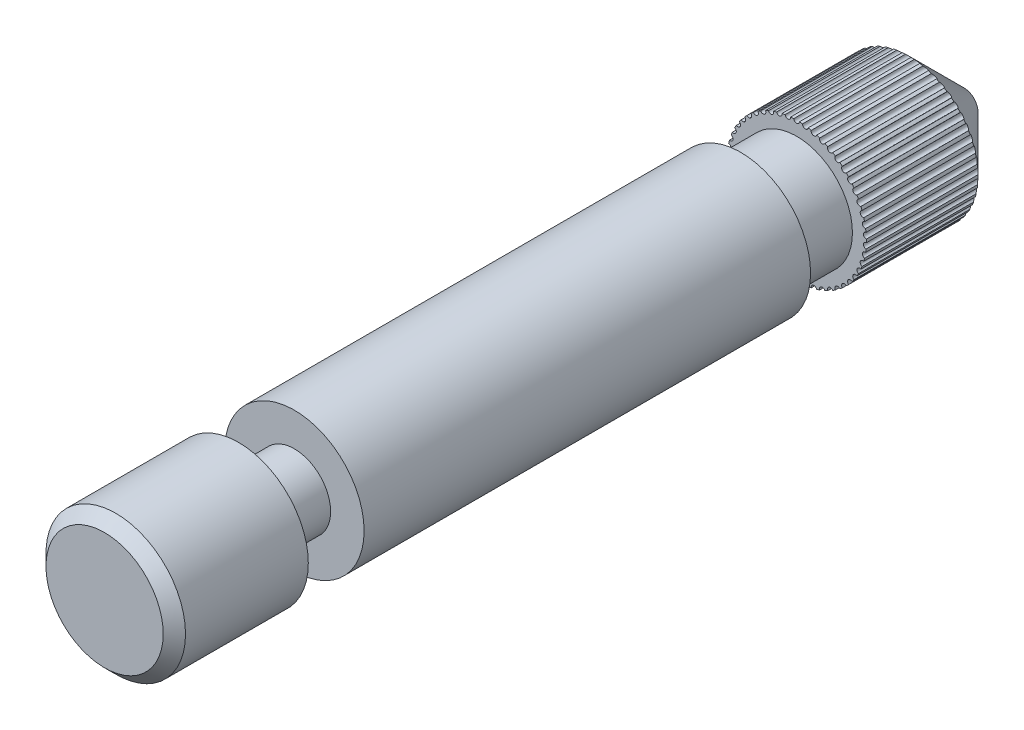
from build123d import *

# Parameters (mm, degrees)
SKETCH1_R           = 1.25
BOSS_EXTRUDE1_DEPTH = 15.4
SKETCH2_W           = 1
SKETCH2_H           = 0.6
SKETCH3_W           = 1
SKETCH3_H           = 0.25
CHAMFER1_SIZE       = 1
CHAMFER2_SIZE       = 0.2
CUT_EXTRUDE2_START  = -2.05
SKETCH4_R           = 0.05
CUT_EXTRUDE2_DEPTH  = 2.05
CIRPATTERN2_COUNT   = 50


with BuildPart() as part:
    # Sketch1 → Boss-Extrude1 (new body)
    with BuildSketch(Plane.XY):
        Circle(SKETCH1_R)
    extrude(amount=-BOSS_EXTRUDE1_DEPTH)

    # Sketch2 → Cut-Revolve1 (revolve, cut)
    with BuildSketch(Plane(origin=(0, 0, 0), x_dir=(0, 0, -1), z_dir=(1, 0, 0))):
        with Locations((2.9, 0.95)):
            Rectangle(SKETCH2_W, SKETCH2_H)
    revolve(axis=Axis((0, 0, 0), (0, 0, -1)), mode=Mode.SUBTRACT)

    # Sketch3 → Cut-Revolve2 (revolve, cut)
    with BuildSketch(Plane(origin=(0, 0, 0), x_dir=(0, 0, -1), z_dir=(1, 0, 0))):
        with Locations((11.9, 1.125)):
            Rectangle(SKETCH3_W, SKETCH3_H)
    revolve(axis=Axis((0, 0, 0), (0, 0, -1)), mode=Mode.SUBTRACT)

    # Chamfer1
    chamfer1_edges = [part.edges().sort_by_distance(p)[0] for p in [
        (-1.25, 0, -15.4),
    ]]
    chamfer(chamfer1_edges, length=CHAMFER1_SIZE)

    # Chamfer2
    chamfer2_edges = [part.edges().sort_by_distance(p)[0] for p in [
        (-1.25, 0, 0),
    ]]
    chamfer(chamfer2_edges, length=CHAMFER2_SIZE)

    # Sketch4 → Cut-Extrude2 (cut)
    with BuildSketch(Plane.XY.offset(-12.4).offset(CUT_EXTRUDE2_START)):
        with Locations((0, 1.25)):
            Circle(SKETCH4_R)
    cut_extrude2 = extrude(amount=CUT_EXTRUDE2_DEPTH, mode=Mode.SUBTRACT)

    # CirPattern2: Cut-Extrude2 ×50 about axis
    cirpattern2_axis = Axis((0, 0, 0), (0, 0, 1))
    for i in range(1, CIRPATTERN2_COUNT):
        add(cut_extrude2.rotate(cirpattern2_axis, i * 360 / CIRPATTERN2_COUNT), mode=Mode.SUBTRACT)


solid = part.part
